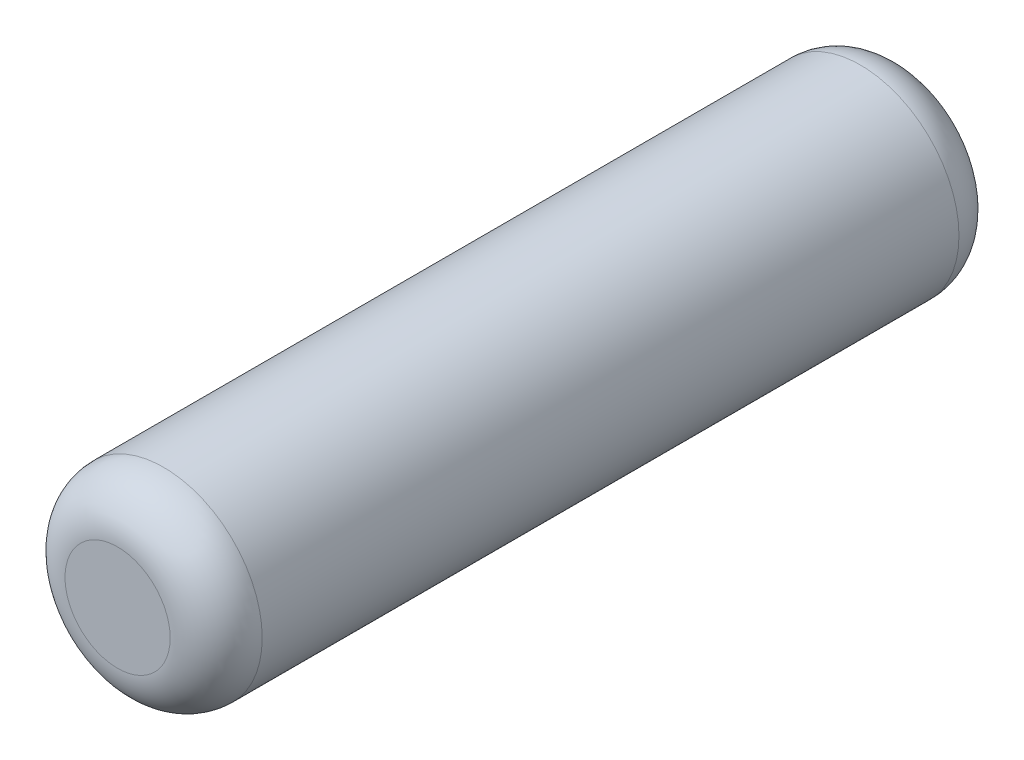
from build123d import *

# Parameters (mm, degrees)
SKETCH1_R           = 0.75
BOSS_EXTRUDE1_DEPTH = 3
FILLET1_R           = 0.35


with BuildPart() as part:
    # Sketch1 → Boss-Extrude1 (new body, symmetric)
    with BuildSketch(Plane.XY):
        Circle(SKETCH1_R)
    extrude(amount=BOSS_EXTRUDE1_DEPTH, both=True)

    # Fillet1
    fillet1_edges = [part.edges().sort_by_distance(p)[0] for p in [
        (-0.75, 0, -3),
        (-0.75, 0, 3),
    ]]
    fillet(fillet1_edges, radius=FILLET1_R)


solid = part.part
